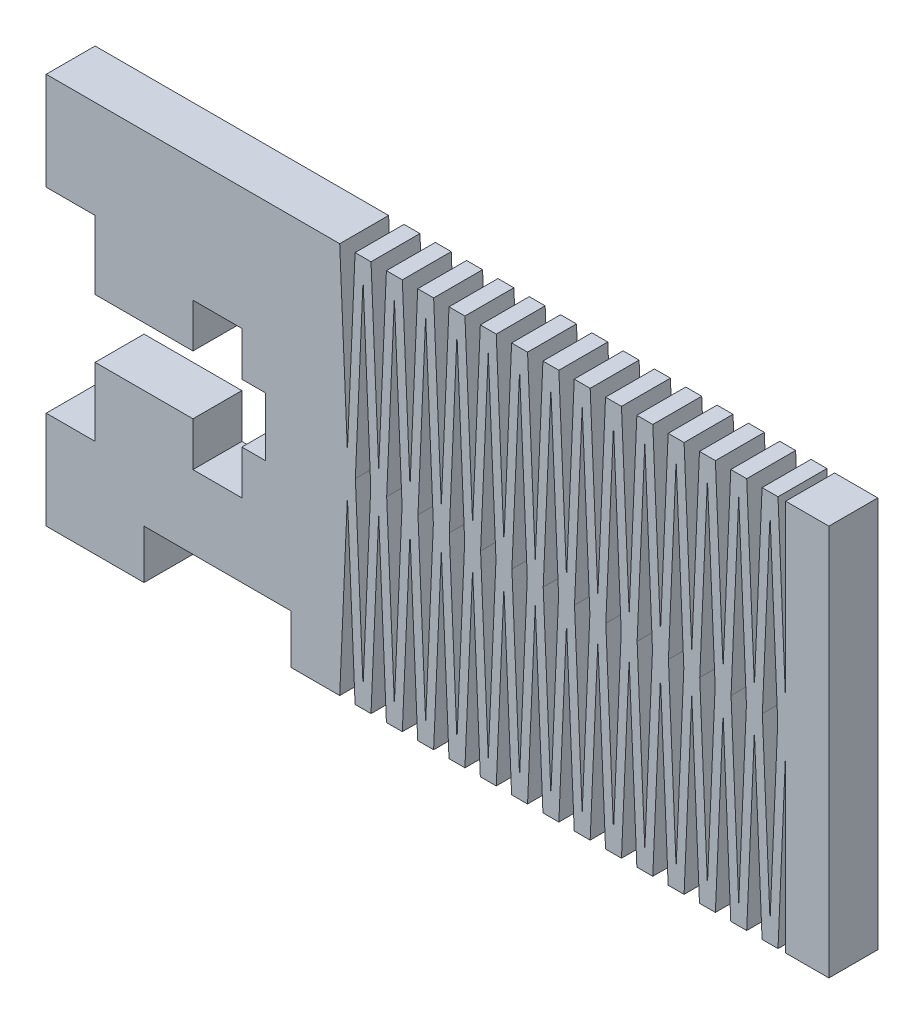
from build123d import *

# Parameters (mm, degrees)
BOSS_EXTRUDE2_DEPTH = 3.175


with BuildPart() as part:
    # Sketch1 → Boss-Extrude2 (new body)
    with BuildSketch(Plane.XY):
        Polygon((0, 6.35), (0, 0), (6.35, 0), (6.35, 3.175), (15.875, 3.175), (15.875, 0), (19.05, 0), (19.549044577, 11.43), (20.048089155, 0), (21.082, 0), (21.581044577, 11.43), (22.080089155, 0), (23.114, 0), (23.613044577, 11.43), (24.112089155, 0), (25.146, 0), (25.645044577, 11.43), (26.144089155, 0), (27.178, 0), (27.677044577, 11.43), (28.176089155, 0), (29.21, 0), (29.709044577, 11.43), (30.208089155, 0), (31.242, 0), (31.741044577, 11.43), (32.240089155, 0), (33.274, 0), (33.773044577, 11.43), (34.272089155, 0), (35.306, 0), (35.805044577, 11.43), (36.304089155, 0), (37.338, 0), (37.837044577, 11.43), (38.336089155, 0), (39.37, 0), (39.869044577, 11.43), (40.368089155, 0), (41.402, 0), (41.901044577, 11.43), (42.400089155, 0), (43.434, 0), (43.933044577, 11.43), (44.432089155, 0), (45.466, 0), (45.965044577, 11.43), (46.464089155, 0), (47.498, 0), (47.997044577, 11.43), (47.997044577, 0), (50.8, 0), (50.8, 25.4), (47.997044577, 25.4), (47.997044577, 13.97), (47.498, 25.4), (46.464089155, 25.4), (45.965044577, 13.97), (45.466, 25.4), (44.432089155, 25.4), (43.933044577, 13.97), (43.434, 25.4), (42.400089155, 25.4), (41.901044577, 13.97), (41.402, 25.4), (40.368089155, 25.4), (39.869044577, 13.97), (39.37, 25.4), (38.336089155, 25.4), (37.837044577, 13.97), (37.338, 25.4), (36.304089155, 25.4), (35.805044577, 13.97), (35.306, 25.4), (34.272089155, 25.4), (33.773044577, 13.97), (33.274, 25.4), (32.240089155, 25.4), (31.741044577, 13.97), (31.242, 25.4), (30.208089155, 25.4), (29.709044577, 13.97), (29.21, 25.4), (28.176089155, 25.4), (27.677044577, 13.97), (27.178, 25.4), (26.144089155, 25.4), (25.645044577, 13.97), (25.146, 25.4), (24.112089155, 25.4), (23.613044577, 13.97), (23.114, 25.4), (22.080089155, 25.4), (21.581044577, 13.97), (21.082, 25.4), (20.048089155, 25.4), (19.549044577, 13.97), (19.05, 25.4), (0, 25.4), (0, 19.05), (3.175, 19.05), (3.175, 14.605), (9.525, 14.605), (9.525, 17.4625), (12.7, 17.4625), (12.7, 14.605), (14.224, 14.605), (14.224, 10.795), (12.7, 10.795), (12.7, 7.9375), (9.525, 7.9375), (9.525, 10.795), (3.175, 10.795), (3.175, 6.35), align=None)
        Polygon((20.066, 12.7), (20.565044577, 24.13), (21.064089155, 12.7), (20.565044577, 1.27), align=None, mode=Mode.SUBTRACT)
        Polygon((22.098, 12.7), (22.597044577, 24.13), (23.096089155, 12.7), (22.597044577, 1.27), align=None, mode=Mode.SUBTRACT)
        Polygon((24.13, 12.7), (24.629044577, 24.13), (25.128089155, 12.7), (24.629044577, 1.27), align=None, mode=Mode.SUBTRACT)
        Polygon((26.162, 12.7), (26.661044577, 24.13), (27.160089155, 12.7), (26.661044577, 1.27), align=None, mode=Mode.SUBTRACT)
        Polygon((28.194, 12.7), (28.693044577, 24.13), (29.192089155, 12.7), (28.693044577, 1.27), align=None, mode=Mode.SUBTRACT)
        Polygon((30.226, 12.7), (30.725044577, 24.13), (31.224089155, 12.7), (30.725044577, 1.27), align=None, mode=Mode.SUBTRACT)
        Polygon((32.258, 12.7), (32.757044577, 24.13), (33.256089155, 12.7), (32.757044577, 1.27), align=None, mode=Mode.SUBTRACT)
        Polygon((34.29, 12.7), (34.789044577, 24.13), (35.288089155, 12.7), (34.789044577, 1.27), align=None, mode=Mode.SUBTRACT)
        Polygon((36.322, 12.7), (36.821044577, 24.13), (37.320089155, 12.7), (36.821044577, 1.27), align=None, mode=Mode.SUBTRACT)
        Polygon((38.354, 12.7), (38.853044577, 24.13), (39.352089155, 12.7), (38.853044577, 1.27), align=None, mode=Mode.SUBTRACT)
        Polygon((40.386, 12.7), (40.885044577, 24.13), (41.384089155, 12.7), (40.885044577, 1.27), align=None, mode=Mode.SUBTRACT)
        Polygon((42.418, 12.7), (42.917044577, 24.13), (43.416089155, 12.7), (42.917044577, 1.27), align=None, mode=Mode.SUBTRACT)
        Polygon((44.45, 12.7), (44.949044577, 24.13), (45.448089155, 12.7), (44.949044577, 1.27), align=None, mode=Mode.SUBTRACT)
        Polygon((46.482, 12.7), (46.981044577, 24.13), (47.480089155, 12.7), (46.981044577, 1.27), align=None, mode=Mode.SUBTRACT)
    extrude(amount=BOSS_EXTRUDE2_DEPTH)


solid = part.part
